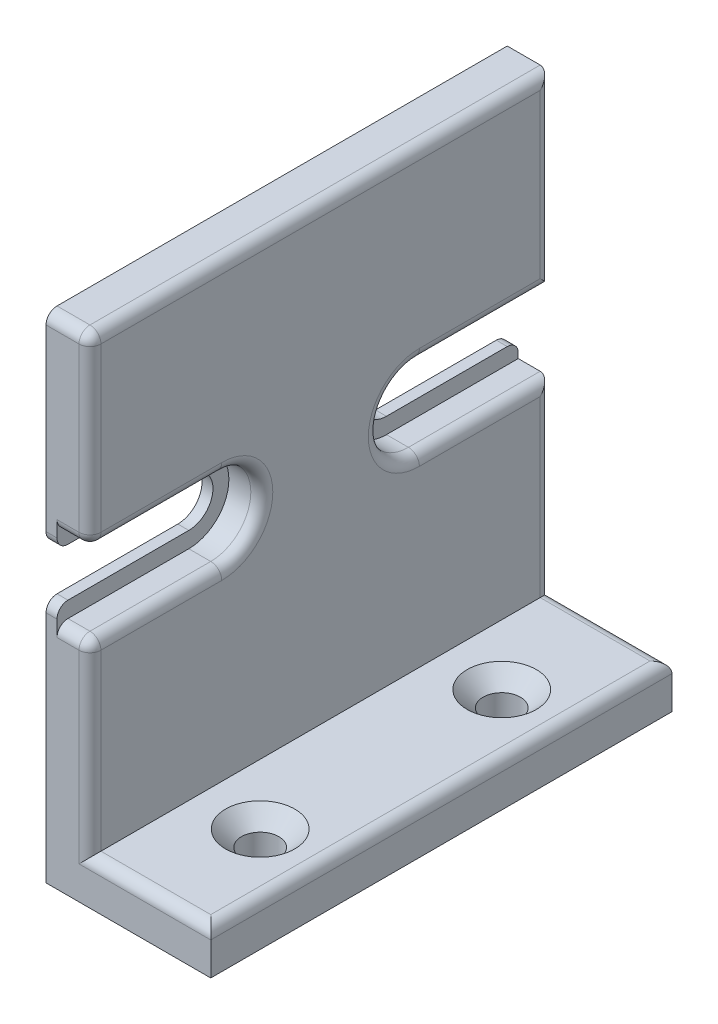
from build123d import *

# Parameters (mm, degrees)
BOSS_EXTRUDE1_DEPTH                             = 42
CUT_EXTRUDE1_DEPTH                              = 3
CUT_EXTRUDE2_DEPTH                              = 2
CSK_FOR_M3_FLAT_HEAD_MACHINE_SCREW1_D           = 3.4
CSK_FOR_M3_FLAT_HEAD_MACHINE_SCREW1_CSINK_D     = 6.3
CSK_FOR_M3_FLAT_HEAD_MACHINE_SCREW1_CSINK_ANGLE = 90
FILLET3_R                                       = 1
FILLET4_R                                       = 1
FILLET5_R                                       = 1
FILLET6_R                                       = 1
FILLET7_R                                       = 1
FILLET8_R                                       = 1


with BuildPart() as part:
    # Sketch1 → Boss-Extrude1 (new body)
    with BuildSketch(Plane.XY):
        Polygon((-124.373548005, 69.489611766), (-124.373548005, 24.489611766), (-109.373548005, 24.489611766), (-109.373548005, 28.489611766), (-120.373548005, 28.489611766), (-120.373548005, 69.489611766), align=None)
    extrude(amount=BOSS_EXTRUDE1_DEPTH)

    # Sketch2 → Cut-Extrude1 (cut)
    with BuildSketch(Plane(origin=(-120.373548005, 0, 0), x_dir=(0, 0, -1), z_dir=(1, 0, 0))):
        with BuildLine():
            Line((-42, 52.639611766), (-30, 52.639611766))
            ThreePointArc((-30, 52.639611766), (-26.35, 48.989611766), (-30, 45.339611766))
            Line((-30, 45.339611766), (-42, 45.339611766))
            Line((-42, 45.339611766), (-42, 52.639611766))
        make_face()
    cut_extrude1 = extrude(amount=-CUT_EXTRUDE1_DEPTH, mode=Mode.SUBTRACT)

    # Sketch4 → Cut-Extrude2 (cut, through all)
    with BuildSketch(Plane(origin=(-123.373548005, 0, 0), x_dir=(0, 0, -1), z_dir=(1, 0, 0))):
        with BuildLine():
            Line((-42, 51.189611766), (-42, 46.789611766))
            Line((-42, 46.789611766), (-30, 46.789611766))
            ThreePointArc((-30, 46.789611766), (-27.8, 48.989611766), (-30, 51.189611766))
            Line((-30, 51.189611766), (-42, 51.189611766))
        make_face()
    cut_extrude2 = extrude(amount=-CUT_EXTRUDE2_DEPTH, mode=Mode.SUBTRACT)

    # Mirror2: Cut-Extrude1, Cut-Extrude2 across plane
    add(cut_extrude1.mirror(Plane.XY.offset(21)), mode=Mode.SUBTRACT)
    add(cut_extrude2.mirror(Plane.XY.offset(21)), mode=Mode.SUBTRACT)

    # CSK for M3 Flat Head Machine Screw1 (through all)
    with Locations(Plane(origin=(0, 28.489611766, 0), x_dir=(1, 0, 0), z_dir=(0, 1, 0))):
        with Locations((-114.873548005, -32), (-114.873548005, -10)):
            CounterSinkHole(CSK_FOR_M3_FLAT_HEAD_MACHINE_SCREW1_D / 2, CSK_FOR_M3_FLAT_HEAD_MACHINE_SCREW1_CSINK_D / 2, counter_sink_angle=CSK_FOR_M3_FLAT_HEAD_MACHINE_SCREW1_CSINK_ANGLE)

    # Fillet3
    fillet3_edges = [part.edges().sort_by_distance(p)[0] for p in [
        (-120.373548005, 36.914611766, 42),
    ]]
    fillet(fillet3_edges, radius=FILLET3_R)

    # Fillet4
    fillet4_edges = [part.edges().sort_by_distance(p)[0] for p in [
        (-120.373548005, 61.064611766, 42),
    ]]
    fillet(fillet4_edges, radius=FILLET4_R)

    # Fillet5
    fillet5_edges = [part.edges().sort_by_distance(p)[0] for p in [
        (-120.666441224, 52.639611766, 41.707106781),
        (-122.373548005, 45.339611766, 42),
        (-122.373548005, 52.639611766, 42),
        (-120.373548005, 48.989611766, 26.35),
        (-120.373548005, 52.639611766, 35.5),
        (-120.373548005, 45.339611766, 35.5),
        (-120.666441224, 45.339611766, 41.707106781),
    ]]
    fillet(fillet5_edges, radius=FILLET5_R)

    # Fillet6
    fillet6_edges = [part.edges().sort_by_distance(p)[0] for p in [
        (-122.873548005, 69.489611766, 42),
        (-120.666441224, 69.489611766, 41.707106781),
        (-114.873548005, 28.489611766, 42),
        (-109.373548005, 28.489611766, 21),
        (-114.873548005, 28.489611766, 0),
        (-120.373548005, 36.914611766, 0),
        (-120.373548005, 48.989611766, 15.65),
        (-120.373548005, 45.339611766, 6),
        (-120.373548005, 52.639611766, 6),
        (-120.373548005, 61.064611766, 0),
        (-120.373548005, 69.489611766, 20.5),
    ]]
    fillet(fillet6_edges, radius=FILLET6_R)

    # Fillet7
    fillet7_edges = [part.edges().sort_by_distance(p)[0] for p in [
        (-123.873548005, 51.189611766, 42),
    ]]
    fillet(fillet7_edges, radius=FILLET7_R)

    # Fillet8
    fillet8_edges = [part.edges().sort_by_distance(p)[0] for p in [
        (-123.873548005, 46.789611766, 42),
        (-123.873548005, 51.189611766, 0),
        (-123.873548005, 46.789611766, 0),
    ]]
    fillet(fillet8_edges, radius=FILLET8_R)


solid = part.part
